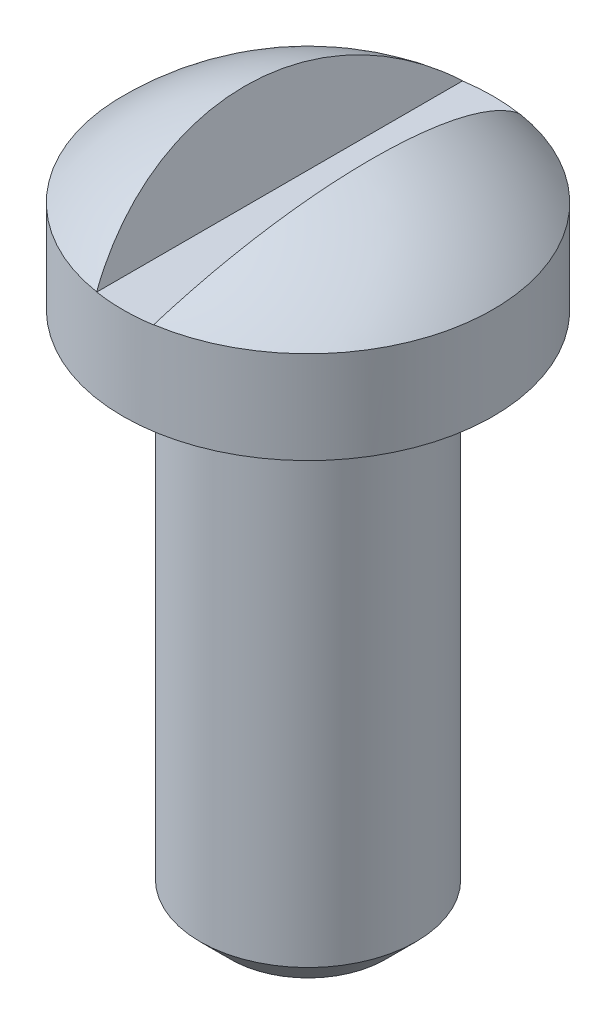
from build123d import *

# Parameters (mm, degrees)
CHAMFER1_SIZE           = 2.54
DOME1_FACE_RADIUS       = 15.24
DOME1_HEIGHT            = 6.35
CUT_EXTRUDE5_DEPTH      = 16.24
CUT_EXTRUDE5_DEPTH_BACK = 16.24


with BuildPart() as part:
    # Sketch2 → Revolve-Thin2 (revolve)
    with BuildSketch(Plane.XY):
        Polygon((0, -85.867755946), (-6.35, -85.867755946), (-6.35, -42.687755946), (-12.7, -42.687755946), (-12.7, -40.147755946), (0, -40.147755946), (0, -37.607755946), (-15.24, -37.607755946), (-15.24, -45.227755946), (-8.89, -45.227755946), (-8.89, -88.407755946), (0, -88.407755946), align=None)
    revolve(axis=Axis((0, -25.732100586, 0), (0, -1, 0)))

    # Chamfer1
    chamfer1_edges = [part.edges().sort_by_distance(p)[0] for p in [
        (8.89, -88.407755946, 0),
    ]]
    chamfer(chamfer1_edges, length=CHAMFER1_SIZE)

    # Dome1: a dome of height H over a round flat face of radius A is a cap of a sphere of radius (A * A + H * H) / (2 * H)
    dome1_r = (DOME1_FACE_RADIUS * DOME1_FACE_RADIUS + DOME1_HEIGHT * DOME1_HEIGHT) / (2 * DOME1_HEIGHT)
    dome1_base = Plane((0, -37.607755946, 0), z_dir=(0, 1, 0))
    with Locations(dome1_base.offset(DOME1_HEIGHT - dome1_r)):
        dome1_ball = Sphere(dome1_r, mode=Mode.PRIVATE)
    add(split(dome1_ball, bisect_by=dome1_base, keep=Keep.TOP, mode=Mode.PRIVATE))

    # Sketch15 → Cut-Extrude5 (cut, two sides)
    with BuildSketch(Plane.XY) as cut_extrude5_sk:
        Polygon((63.582364053, 84.47121169), (5.21254128, -31.900338505), (2.340727282, -37.625856093), (-2.340727282, -37.625856093), (-5.21254128, -31.900338505), (-63.582364053, 84.47121169), (-63.582364053, 344.850733967), (63.582364053, 344.850733967), align=None)
    extrude(amount=CUT_EXTRUDE5_DEPTH, mode=Mode.SUBTRACT)
    extrude(cut_extrude5_sk.sketch, amount=-CUT_EXTRUDE5_DEPTH_BACK, mode=Mode.SUBTRACT)


solid = part.part
